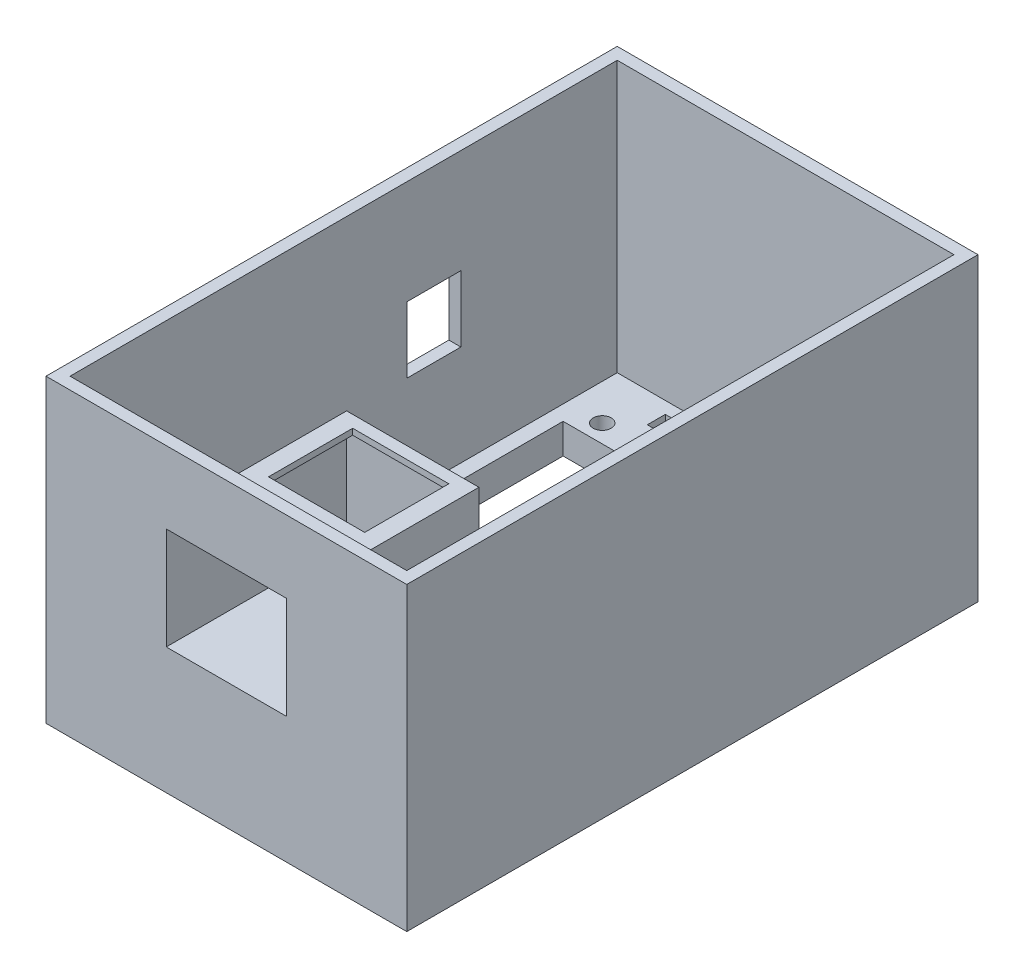
from build123d import *

# Parameters (mm, degrees)
SKETCH_2_W          = 60
SKETCH_2_H          = 95
EXTRUDE_1_DEPTH     = 45
SKETCH_3_W          = 56
SKETCH_3_H          = 91
CUT_EXTRUDE_1_DEPTH = 40
SKETCH_5_W          = 51
SKETCH_5_H          = 70
CUT_EXTRUDE_2_DEPTH = 5
SKETCH_6_R          = 1.5
CUT_EXTRUDE_3_DEPTH = 5
SKETCH_8_R          = 2.75
CUT_EXTRUDE_4_DEPTH = 2.5
SKETCH_10_W         = 36
SKETCH_10_H         = 3
CUT_EXTRUDE_5_DEPTH = 2
SKETCH_11_W         = 60
SKETCH_11_H         = 95
EXTRUDE_2_DEPTH     = 5
SKETCH_12_W         = 56
SKETCH_12_H         = 91
CUT_EXTRUDE_6_DEPTH = 5
SKETCH_13_W         = 9
SKETCH_13_H         = 11
CUT_EXTRUDE_7_DEPTH = 5
SKETCH_14_W         = 22
SKETCH_14_H         = 19
EXTRUDE_3_DEPTH     = 31
SKETCH_15_W         = 20
SKETCH_15_H         = 17
CUT_EXTRUDE_8_DEPTH = 30
SKETCH_16_W         = 16
SKETCH_16_H         = 14
CUT_EXTRUDE_9_DEPTH = 2


with BuildPart() as part:
    # 草圖2 → 填料-伸長1 (new body)
    with BuildSketch(Plane(origin=(0, 0, 0), x_dir=(1, 0, 0), z_dir=(0, 1, 0))):
        with Locations((30, 47.5)):
            Rectangle(SKETCH_2_W, SKETCH_2_H)
    extrude(amount=EXTRUDE_1_DEPTH)

    # 草圖3 → 除料-伸長1 (cut)
    with BuildSketch(Plane(origin=(0, 45, 0), x_dir=(1, 0, 0), z_dir=(0, 1, 0))):
        with Locations((30, 47.5)):
            Rectangle(SKETCH_3_W, SKETCH_3_H)
    extrude(amount=-CUT_EXTRUDE_1_DEPTH, mode=Mode.SUBTRACT)

    # 草圖5 → 除料-伸長2 (cut)
    with BuildSketch(Plane(origin=(0, 5, 0), x_dir=(1, 0, 0), z_dir=(0, 1, 0))):
        with Locations((30, 46.5)):
            Rectangle(SKETCH_5_W, SKETCH_5_H)
    extrude(amount=-CUT_EXTRUDE_2_DEPTH, mode=Mode.SUBTRACT)

    # 草圖6 → 除料-伸長3 (cut)
    with BuildSketch(Plane(origin=(0, 5, 0), x_dir=(1, 0, 0), z_dir=(0, 1, 0))):
        with Locations(Location((8, 8.5, 0), (0, 0, 270))):  # turned: the seam where the file's is
            Circle(SKETCH_6_R)
        with Locations(Location((52, 8.5, 0), (0, 0, 270))):  # turned: the seam where the file's is
            Circle(SKETCH_6_R)
        with Locations(Location((8, 84.5, 0), (0, 0, 270))):  # turned: the seam where the file's is
            Circle(SKETCH_6_R)
        with Locations(Location((52, 84.5, 0), (0, 0, 270))):  # turned: the seam where the file's is
            Circle(SKETCH_6_R)
    extrude(amount=-CUT_EXTRUDE_3_DEPTH, mode=Mode.SUBTRACT)

    # 草圖8 → 除料-伸長4 (cut)
    with BuildSketch(Plane(origin=(0, 0, 0), x_dir=(-1, 0, 0), z_dir=(0, -1, 0))):
        with Locations(Location((-8, 84.5, 0), (0, 0, 90))):  # turned: the seam where the file's is
            Circle(SKETCH_8_R)
        with Locations(Location((-8, 8.5, 0), (0, 0, 90))):  # turned: the seam where the file's is
            Circle(SKETCH_8_R)
        with Locations(Location((-52, 8.5, 0), (0, 0, 90))):  # turned: the seam where the file's is
            Circle(SKETCH_8_R)
        with Locations(Location((-52, 84.5, 0), (0, 0, 90))):  # turned: the seam where the file's is
            Circle(SKETCH_8_R)
    extrude(amount=-CUT_EXTRUDE_4_DEPTH, mode=Mode.SUBTRACT)

    # 草圖10 → 除料-伸長5 (cut)
    with BuildSketch(Plane(origin=(0, 5, 0), x_dir=(1, 0, 0), z_dir=(0, 1, 0))):
        with Locations((30, 89.5)):
            Rectangle(SKETCH_10_W, SKETCH_10_H)
    extrude(amount=-CUT_EXTRUDE_5_DEPTH, mode=Mode.SUBTRACT)

    # 草圖11 → 填料-伸長2 (add)
    with BuildSketch(Plane.XZ.offset(-45)):
        with Locations((30, -47.5)):
            Rectangle(SKETCH_11_W, SKETCH_11_H)
    extrude(amount=-EXTRUDE_2_DEPTH)

    # 草圖12 → 除料-伸長6 (cut)
    with BuildSketch(Plane(origin=(0, 50, 0), x_dir=(1, 0, 0), z_dir=(0, 1, 0))):
        with Locations((30, 47.5)):
            Rectangle(SKETCH_12_W, SKETCH_12_H)
    extrude(amount=-CUT_EXTRUDE_6_DEPTH, mode=Mode.SUBTRACT)

    # 草圖13 → 除料-伸長7 (cut)
    with BuildSketch(Plane.ZY):
        with Locations((-62.5, 27.2)):
            Rectangle(SKETCH_13_W, SKETCH_13_H)
    extrude(amount=-CUT_EXTRUDE_7_DEPTH, mode=Mode.SUBTRACT)

    # 草圖14 → 填料-伸長3 (add)
    with BuildSketch(Plane.XY):
        with Locations((30, 29.5)):
            Rectangle(SKETCH_14_W, SKETCH_14_H)
    extrude(amount=-EXTRUDE_3_DEPTH)

    # 草圖15 → 除料-伸長8 (cut)
    with BuildSketch(Plane.XY):
        with Locations((30, 29.5)):
            Rectangle(SKETCH_15_W, SKETCH_15_H)
    extrude(amount=-CUT_EXTRUDE_8_DEPTH, mode=Mode.SUBTRACT)

    # 草圖16 → 除料-伸長9 (cut)
    with BuildSketch(Plane(origin=(0, 39, 0), x_dir=(1, 0, 0), z_dir=(0, 1, 0))):
        with Locations((30, 22)):
            Rectangle(SKETCH_16_W, SKETCH_16_H)
    extrude(amount=-CUT_EXTRUDE_9_DEPTH, mode=Mode.SUBTRACT)


solid = part.part
